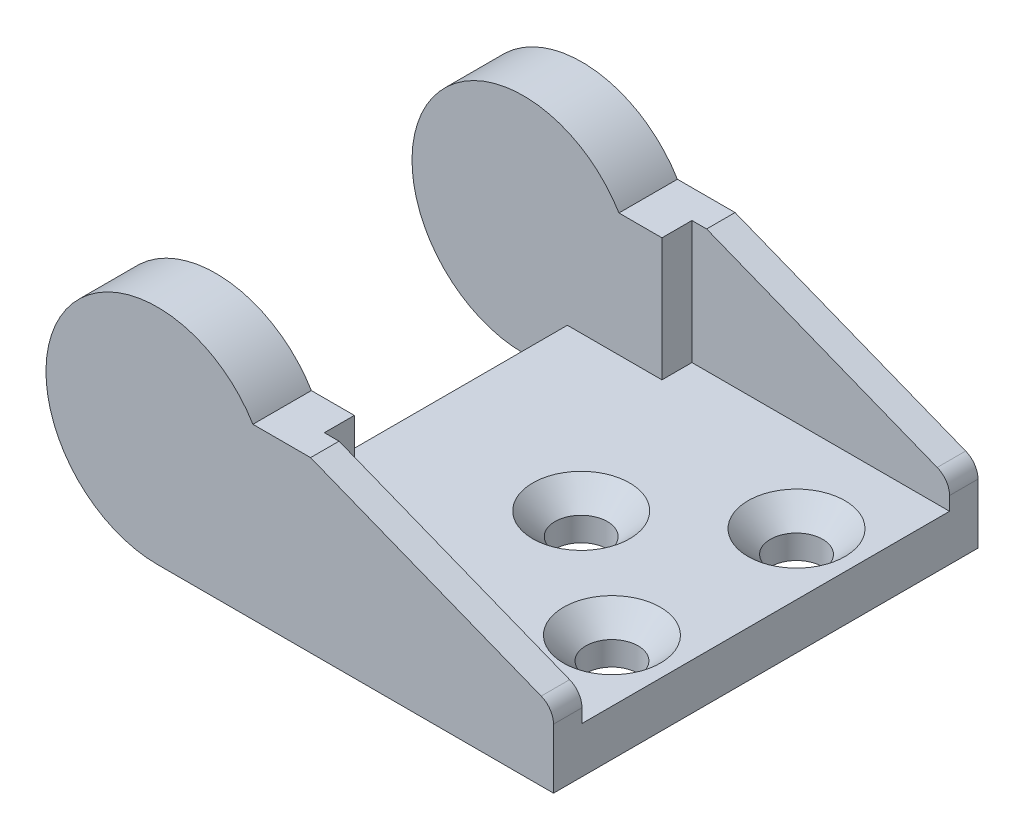
from build123d import *

# Parameters (mm, degrees)
BOSS_EXTRUDE1_DEPTH                            = 13.8
SKETCH2_W                                      = 16.75
SKETCH2_H                                      = 23.9
CUT_EXTRUDE1_DEPTH                             = 8.25
CUT_EXTRUDE1_DEPTH_BACK                        = 4.25
SKETCH3_W                                      = 10.1
SKETCH3_H                                      = 20
CUT_EXTRUDE2_DEPTH                             = 15.5
SKETCH4_W                                      = 6.15
SKETCH4_H                                      = 20
CUT_EXTRUDE3_DEPTH                             = 12.5
FILLET1_R                                      = 1.27
CSK_FOR_M3_FLAT_HEAD_MACHINE_SCREW1_AT_2_COUNT = 2
CSK_FOR_M3_FLAT_HEAD_MACHINE_SCREW1_AT_2_PITCH = 10
CSK_FOR_M3_FLAT_HEAD_MACHINE_SCREW1_AT_3_COUNT = 2
CSK_FOR_M3_FLAT_HEAD_MACHINE_SCREW1_AT_3_PITCH = 12


with BuildPart() as part:
    # Sketch1 → Boss-Extrude1 (new body, symmetric)
    with BuildSketch(Plane.XY):
        with BuildLine():
            Line((0, -7.25), (25.75, -7.25))
            Line((25.75, -7.25), (25.75, -2.5))
            Line((25.75, -2.5), (9.954836823, 3.75))
            Line((9.954836823, 3.75), (6.204836823, 3.75))
            ThreePointArc((6.204836823, 3.75), (-6.31466547, 3.561951712), (0, -7.25))
        make_face()
    extrude(amount=BOSS_EXTRUDE1_DEPTH, both=True)

    # Sketch2 → Cut-Extrude1 (cut, two sides)
    with BuildSketch(Plane(origin=(0, 0, 0), x_dir=(1, 0, 0), z_dir=(0, 1, 0))) as cut_extrude1_sk:
        with Locations((17.375, 0)):
            Rectangle(SKETCH2_W, SKETCH2_H)
    extrude(amount=CUT_EXTRUDE1_DEPTH, mode=Mode.SUBTRACT)
    extrude(cut_extrude1_sk.sketch, amount=-CUT_EXTRUDE1_DEPTH_BACK, mode=Mode.SUBTRACT)

    # Sketch3 → Cut-Extrude2 (cut, through all)
    with BuildSketch(Plane.XZ.offset(7.25)):
        with Locations((-2.2, 0)):
            Rectangle(SKETCH3_W, SKETCH3_H)
    extrude(amount=-CUT_EXTRUDE2_DEPTH, mode=Mode.SUBTRACT)

    # Sketch4 → Cut-Extrude3 (cut, through all)
    with BuildSketch(Plane(origin=(0, -4.25, 0), x_dir=(1, 0, 0), z_dir=(0, 1, 0))):
        with Locations((5.925, 0)):
            Rectangle(SKETCH4_W, SKETCH4_H)
    extrude(amount=CUT_EXTRUDE3_DEPTH, mode=Mode.SUBTRACT)

    # Fillet1
    fillet1_edges = [part.edges().sort_by_distance(p)[0] for p in [
        (25.75, -2.5, -12.875),
        (25.75, -2.5, 12.875),
    ]]
    fillet(fillet1_edges, radius=FILLET1_R)

    # Sketch6 → CSK for M3 Flat Head Machine Screw1 (revolve, cut)
    with BuildSketch(Plane(origin=(21.75, -4.25, -6), x_dir=(0, 0, 1), z_dir=(1, 0, 0))):
        Polygon((0, 0), (0, 3), (1.7, 3), (1.7, 1.45), (3.15, 0), align=None)
    csk_for_m3_flat_head_machine_screw1 = revolve(axis=Axis((21.75, 2.1, -6), (0, -1, 0)), mode=Mode.SUBTRACT)

    # CSK for M3 Flat Head Machine Screw1 at 2: CSK for M3 Flat Head Machine Screw1 ×2
    with Locations(*[Vector(-0.8, 0, 0.6) * (i * CSK_FOR_M3_FLAT_HEAD_MACHINE_SCREW1_AT_2_PITCH) for i in range(1, CSK_FOR_M3_FLAT_HEAD_MACHINE_SCREW1_AT_2_COUNT)]):
        add(csk_for_m3_flat_head_machine_screw1, mode=Mode.SUBTRACT)

    # CSK for M3 Flat Head Machine Screw1 at 3: CSK for M3 Flat Head Machine Screw1 ×2
    with Locations(*[(0, 0, i * CSK_FOR_M3_FLAT_HEAD_MACHINE_SCREW1_AT_3_PITCH) for i in range(1, CSK_FOR_M3_FLAT_HEAD_MACHINE_SCREW1_AT_3_COUNT)]):
        add(csk_for_m3_flat_head_machine_screw1, mode=Mode.SUBTRACT)


solid = part.part
